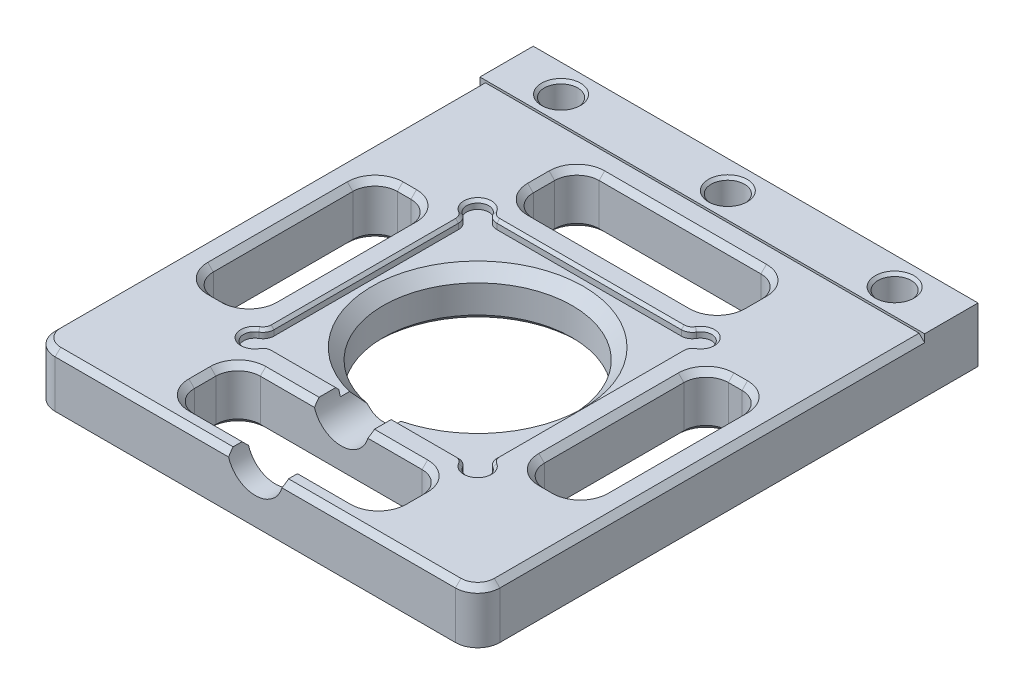
from build123d import *

# Parameters (mm, degrees)
BOSS_EXTRUDE1_DEPTH     = 0.75
SKETCH2_W               = 40
SKETCH2_H               = 45
SKETCH2_R               = 8.5
BOSS_EXTRUDE2_DEPTH     = 4
FILLET1_R               = 1
SKETCH3_R               = 1.5
CUT_EXTRUDE1_DEPTH      = 7
SKETCH4_W               = 40
SKETCH4_H               = 4.8
SKETCH4_R               = 1.5
BOSS_EXTRUDE3_DEPTH     = 0.2
CHAMFER1_SIZE           = 0.25
CHAMFER2_SIZE           = 0.25
CHAMFER3_SIZE           = 1
FILLET2_R               = 2
CHAMFER4_SIZE           = 0.5
SKETCH5_W               = 18.55
SKETCH5_H               = 5.925
SKETCH5_W_2             = 5.225
SKETCH5_H_2             = 16.55
CUT_EXTRUDE2_DEPTH      = 11.2
FILLET3_R               = 2
CHAMFER5_SIZE           = 0.5
SKETCH6_R               = 2.5
CUT_EXTRUDE3_DEPTH      = 11.2
CUT_EXTRUDE3_DEPTH_BACK = 11.2


with BuildPart() as part:
    # Sketch1 → Boss-Extrude1 (new body)
    with BuildSketch(Plane(origin=(0, 0, 0), x_dir=(1, 0, 0), z_dir=(0, 1, 0))):
        Polygon((20, -20), (20, 20), (20, 25), (-20, 25), (-20, 20), (-20, -20), align=None)
        with BuildLine():
            ThreePointArc((-10.025, -9.025), (-10.732106781, -10.732106781), (-9.025, -10.025))
            Line((-9.025, -10.025), (9.025, -10.025))
            ThreePointArc((9.025, -10.025), (10.732106781, -10.732106781), (10.025, -9.025))
            Line((10.025, -9.025), (10.025, 9.025))
            ThreePointArc((10.025, 9.025), (10.732106781, 10.732106781), (9.025, 10.025))
            Line((9.025, 10.025), (-9.025, 10.025))
            ThreePointArc((-9.025, 10.025), (-10.732106781, 10.732106781), (-10.025, 9.025))
            Line((-10.025, 9.025), (-10.025, -9.025))
        make_face(mode=Mode.SUBTRACT)
    extrude(amount=BOSS_EXTRUDE1_DEPTH)

    # Sketch2 → Boss-Extrude2 (add)
    with BuildSketch(Plane.XZ):
        with Locations((0, -2.5)):
            Rectangle(SKETCH2_W, SKETCH2_H)
        Circle(SKETCH2_R, mode=Mode.SUBTRACT)
    extrude(amount=BOSS_EXTRUDE2_DEPTH)

    # Fillet1
    fillet1_edges = [part.edges().sort_by_distance(p)[0] for p in [
        (-9.025, 0.375, 10.025),
        (9.025, 0.375, 10.025),
        (10.025, 0.375, 9.025),
        (10.025, 0.375, -9.025),
        (9.025, 0.375, -10.025),
        (-9.025, 0.375, -10.025),
        (-10.025, 0.375, -9.025),
        (-10.025, 0.375, 9.025),
    ]]
    fillet(fillet1_edges, radius=FILLET1_R)

    # Sketch3 → Cut-Extrude1 (cut)
    with BuildSketch(Plane(origin=(0, 0.75, 0), x_dir=(1, 0, 0), z_dir=(0, 1, 0))):
        with Locations((0, 22.5)):
            Circle(SKETCH3_R)
        with Locations((-15, 22.5)):
            Circle(SKETCH3_R)
        with Locations((15, 22.5)):
            Circle(SKETCH3_R)
    extrude(amount=-CUT_EXTRUDE1_DEPTH, mode=Mode.SUBTRACT)

    # Sketch4 → Boss-Extrude3 (add)
    with BuildSketch(Plane(origin=(0, 0.75, 0), x_dir=(1, 0, 0), z_dir=(0, 1, 0))):
        with Locations((0, 22.6)):
            Rectangle(SKETCH4_W, SKETCH4_H)
        with Locations((15, 22.5)):
            Circle(SKETCH4_R, mode=Mode.SUBTRACT)
        with Locations((0, 22.5)):
            Circle(SKETCH4_R, mode=Mode.SUBTRACT)
        with Locations((-15, 22.5)):
            Circle(SKETCH4_R, mode=Mode.SUBTRACT)
    extrude(amount=BOSS_EXTRUDE3_DEPTH)

    # Chamfer1
    chamfer1_edges = [part.edges().sort_by_distance(p)[0] for p in [
        (13.5, 0.95, -22.5),
        (-1.5, 0.95, -22.5),
        (-16.5, 0.95, -22.5),
    ]]
    chamfer(chamfer1_edges, length=CHAMFER1_SIZE)

    # Chamfer2
    chamfer2_edges = [part.edges().sort_by_distance(p)[0] for p in [
        (0, 0.75, 10.025),
        (10.732106781, 0.75, 10.732106781),
        (-10.732106781, 0.75, 10.732106781),
        (-10.025, 0.75, 0),
        (-10.732106781, 0.75, -10.732106781),
        (0, 0.75, -10.025),
        (10.732106781, 0.75, -10.732106781),
        (10.025, 0.75, 0),
        (-8.792949192, 0.75, -10.158974596),
        (-10.158974596, 0.75, -8.792949192),
        (8.792949192, 0.75, -10.158974596),
        (10.158974596, 0.75, -8.792949192),
        (10.158974596, 0.75, 8.792949192),
        (-10.158974596, 0.75, 8.792949192),
        (-8.792949192, 0.75, 10.158974596),
        (8.792949192, 0.75, 10.158974596),
    ]]
    chamfer(chamfer2_edges, length=CHAMFER2_SIZE)

    # Chamfer3
    chamfer3_edges = [part.edges().sort_by_distance(p)[0] for p in [
        (-8.5, 0, 0),
    ]]
    chamfer(chamfer3_edges, length=CHAMFER3_SIZE)

    # Fillet2
    fillet2_edges = [part.edges().sort_by_distance(p)[0] for p in [
        (20, -1.625, 20),
        (-20, -1.625, 20),
    ]]
    fillet(fillet2_edges, radius=FILLET2_R)

    # Chamfer4
    chamfer4_edges = [part.edges().sort_by_distance(p)[0] for p in [
        (0, 0.75, 20),
        (-20, 0.75, -1.1),
        (20, 0.75, -1.1),
        (19.414213562, 0.75, 19.414213562),
        (-19.414213562, 0.75, 19.414213562),
    ]]
    chamfer(chamfer4_edges, length=CHAMFER4_SIZE)

    # Sketch5 → Cut-Extrude2 (cut)
    with BuildSketch(Plane(origin=(0, 0.75, 0), x_dir=(1, 0, 0), z_dir=(0, 1, 0))):
        with Locations((0, 15.2375)):
            Rectangle(SKETCH5_W, SKETCH5_H)
        with Locations((0, -15.2375)):
            Rectangle(SKETCH5_W, SKETCH5_H)
        with Locations((-14.8875, 0)):
            Rectangle(SKETCH5_W_2, SKETCH5_H_2)
        with Locations((14.8875, 0)):
            Rectangle(SKETCH5_W_2, SKETCH5_H_2)
    extrude(amount=-CUT_EXTRUDE2_DEPTH, mode=Mode.SUBTRACT)

    # Fillet3
    fillet3_edges = [part.edges().sort_by_distance(p)[0] for p in [
        (-9.275, -1.625, -12.275),
        (-9.275, -1.625, -18.2),
        (9.275, -1.625, -18.2),
        (9.275, -1.625, -12.275),
        (-17.5, -1.625, 8.275),
        (-17.5, -1.625, -8.275),
        (-12.275, -1.625, -8.275),
        (-12.275, -1.625, 8.275),
        (-9.275, -1.625, 12.275),
        (9.275, -1.625, 12.275),
        (9.275, -1.625, 18.2),
        (-9.275, -1.625, 18.2),
        (17.5, -1.625, 8.275),
        (12.275, -1.625, 8.275),
        (12.275, -1.625, -8.275),
        (17.5, -1.625, -8.275),
    ]]
    fillet(fillet3_edges, radius=FILLET3_R)

    # Chamfer5
    chamfer5_edges = [part.edges().sort_by_distance(p)[0] for p in [
        (13.5, -4, -22.5),
        (-16.5, -4, -22.5),
        (-1.5, -4, -22.5),
        (-14.8875, -4, 8.275),
        (-14.8875, 0.75, 8.275),
        (-17.5, -4, 0),
        (-17.5, 0.75, 0),
        (-14.8875, -4, -8.275),
        (-14.8875, 0.75, -8.275),
        (-12.275, -4, 0),
        (-12.275, 0.75, 0),
        (0, -4, 12.275),
        (0, 0.75, 12.275),
        (9.275, -4, 15.2375),
        (9.275, 0.75, 15.2375),
        (0, -4, 18.2),
        (0, 0.75, 18.2),
        (-9.275, -4, 15.2375),
        (-9.275, 0.75, 15.2375),
        (14.8875, -4, -8.275),
        (14.8875, 0.75, -8.275),
        (17.5, -4, 0),
        (17.5, 0.75, 0),
        (14.8875, -4, 8.275),
        (14.8875, 0.75, 8.275),
        (12.275, -4, 0),
        (12.275, 0.75, 0),
        (0, -4, -18.2),
        (0, 0.75, -18.2),
        (9.275, -4, -15.2375),
        (9.275, 0.75, -15.2375),
        (0, -4, -12.275),
        (0, 0.75, -12.275),
        (-9.275, -4, -15.2375),
        (-9.275, 0.75, -15.2375),
        (-16.914213562, 0.75, 7.689213562),
        (-16.914213562, -4, 7.689213562),
        (-16.914213562, 0.75, -7.689213562),
        (-16.914213562, -4, -7.689213562),
        (-12.860786438, 0.75, -7.689213562),
        (-12.860786438, -4, -7.689213562),
        (-12.860786438, 0.75, 7.689213562),
        (-12.860786438, -4, 7.689213562),
        (8.689213562, 0.75, 12.860786438),
        (8.689213562, -4, 12.860786438),
        (8.689213562, 0.75, 17.614213562),
        (8.689213562, -4, 17.614213562),
        (-8.689213562, 0.75, 12.860786438),
        (-8.689213562, -4, 12.860786438),
        (-8.689213562, 0.75, 17.614213562),
        (-8.689213562, -4, 17.614213562),
        (16.914213562, 0.75, -7.689213562),
        (16.914213562, -4, -7.689213562),
        (16.914213562, 0.75, 7.689213562),
        (16.914213562, -4, 7.689213562),
        (12.860786438, 0.75, 7.689213562),
        (12.860786438, -4, 7.689213562),
        (12.860786438, 0.75, -7.689213562),
        (12.860786438, -4, -7.689213562),
        (8.689213562, 0.75, -17.614213562),
        (8.689213562, -4, -17.614213562),
        (8.689213562, 0.75, -12.860786438),
        (8.689213562, -4, -12.860786438),
        (-8.689213562, 0.75, -12.860786438),
        (-8.689213562, -4, -12.860786438),
        (-8.689213562, 0.75, -17.614213562),
        (-8.689213562, -4, -17.614213562),
        (-8.5, -4, 0),
    ]]
    chamfer(chamfer5_edges, length=CHAMFER5_SIZE)

    # Sketch6 → Cut-Extrude3 (cut, two sides)
    with BuildSketch(Plane.XY.offset(12.275)) as cut_extrude3_sk:
        with Locations((0, 0.95)):
            Circle(SKETCH6_R)
    extrude(amount=CUT_EXTRUDE3_DEPTH, mode=Mode.SUBTRACT)
    extrude(cut_extrude3_sk.sketch, amount=-CUT_EXTRUDE3_DEPTH_BACK, mode=Mode.SUBTRACT)


solid = part.part
